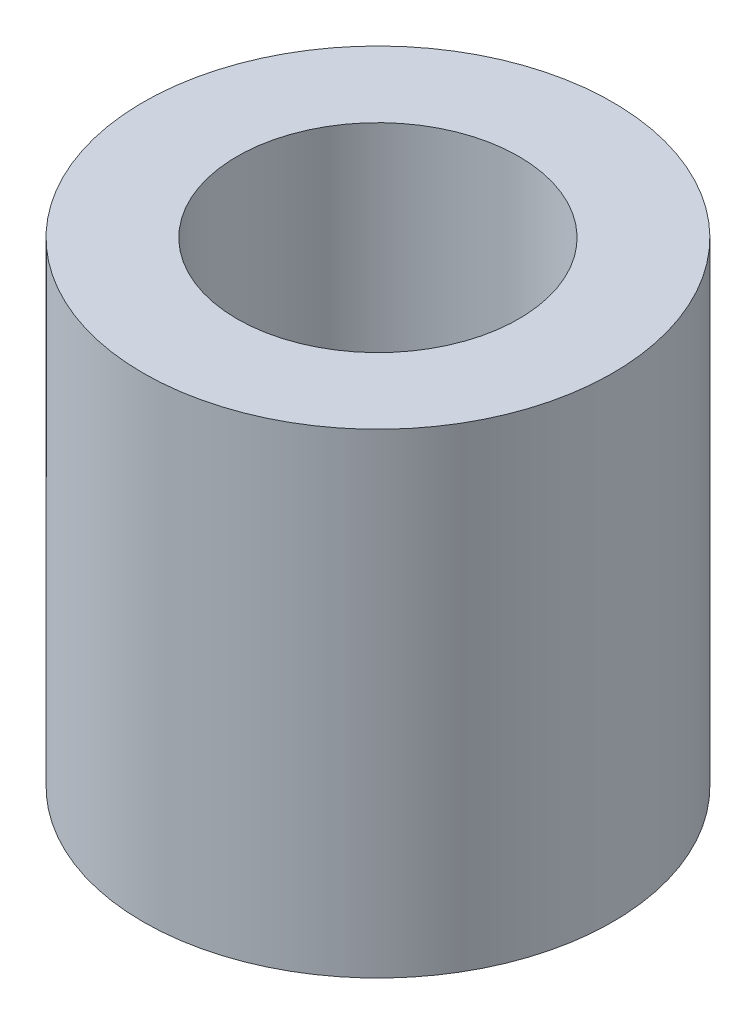
from build123d import *

# Parameters (mm, degrees)
SKETCH1_R           = 4.445
SKETCH1_R_2         = 2.667
BOSS_EXTRUDE1_DEPTH = 9


with BuildPart() as part:
    # Sketch1 → Boss-Extrude1 (new body)
    with BuildSketch(Plane(origin=(0, 0, 0), x_dir=(1, 0, 0), z_dir=(0, 1, 0))):
        Circle(SKETCH1_R)
        Circle(SKETCH1_R_2, mode=Mode.SUBTRACT)
    extrude(amount=BOSS_EXTRUDE1_DEPTH)


solid = part.part
